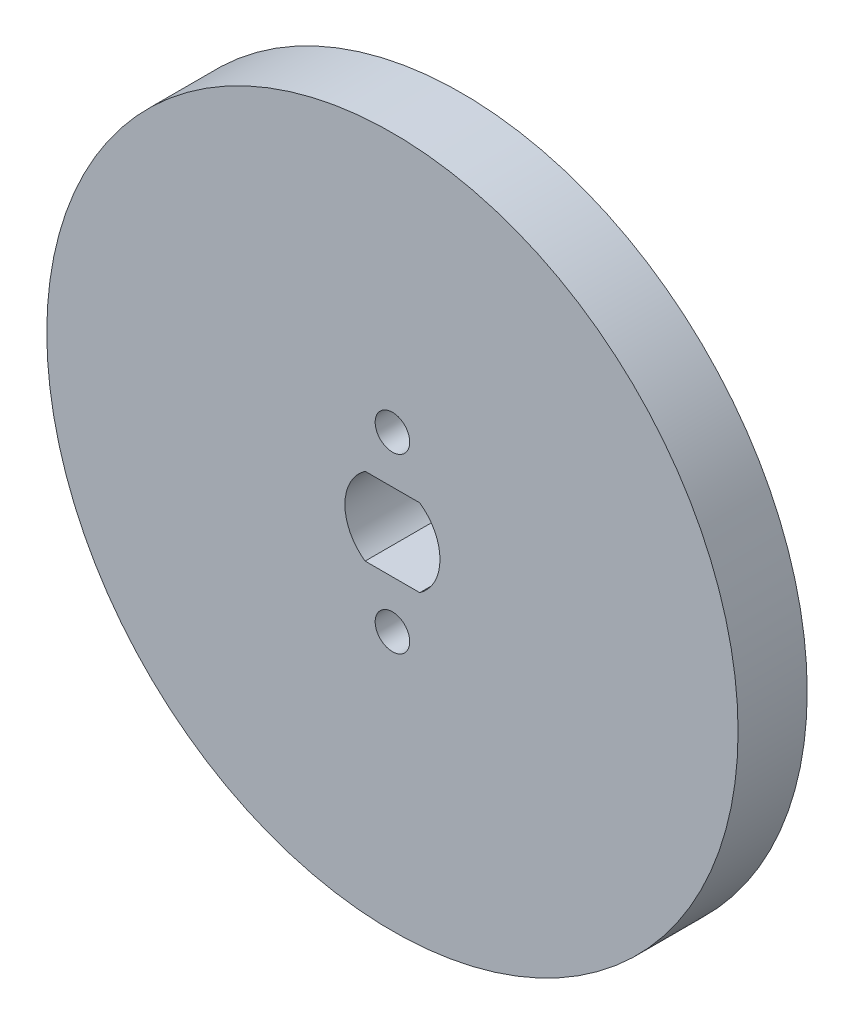
from build123d import *

# Parameters (mm, degrees)
SKETCH_1_R          = 20
EXTRUDE_1_DEPTH     = 4
SKETCH_2_R          = 1
CUT_EXTRUDE_1_DEPTH = 4


with BuildPart() as part:
    # Эскиз1 → Бобышка-Вытянуть1 (new body)
    with BuildSketch(Plane.XY):
        Circle(SKETCH_1_R)
    extrude(amount=EXTRUDE_1_DEPTH)

    # Эскиз2 → Вырез-Вытянуть1 (cut)
    with BuildSketch(Plane.XY.offset(4)):
        with Locations((0, 5)):
            Circle(SKETCH_2_R)
        with Locations((0, -5)):
            Circle(SKETCH_2_R)
        with BuildLine():
            Line((-1.58113883, 2.25), (1.58113883, 2.25))
            ThreePointArc((1.58113883, 2.25), (2.75, 0), (1.58113883, -2.25))
            Line((1.58113883, -2.25), (-1.58113883, -2.25))
            ThreePointArc((-1.58113883, -2.25), (-2.75, 0), (-1.58113883, 2.25))
        make_face()
    extrude(amount=-CUT_EXTRUDE_1_DEPTH, mode=Mode.SUBTRACT)


solid = part.part
